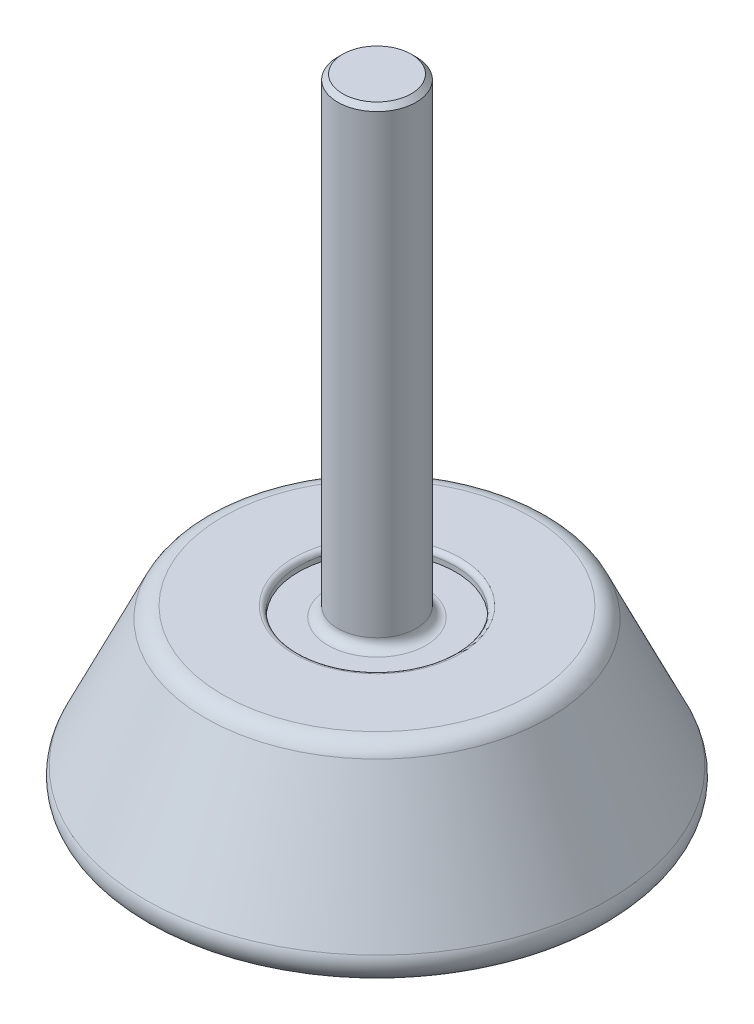
from build123d import *

# Parameters (mm, degrees)
REDONDEO1_R   = 2
REDONDEO2_R   = 1
REDONDEO3_R   = 0.5
CHAFL_N1_SIZE = 0.5


with BuildPart() as part:
    # Croquis2 → Revolución1 (revolve)
    with BuildSketch(Plane.XY):
        Polygon((0, 0), (25, 0), (17, 17), (8, 17), (8, 16), (4, 16), (4, 64), (0, 64), align=None)
    revolve(axis=Axis((0, 64, 0), (0, -1, 0)))

    # Redondeo1
    redondeo1_edges = [part.edges().sort_by_distance(p)[0] for p in [
        (-17, 17, 0),
        (-25, 0, 0),
    ]]
    fillet(redondeo1_edges, radius=REDONDEO1_R)

    # Redondeo2
    redondeo2_edges = [part.edges().sort_by_distance(p)[0] for p in [
        (-4, 16, 0),
    ]]
    fillet(redondeo2_edges, radius=REDONDEO2_R)

    # Redondeo3
    redondeo3_edges = [part.edges().sort_by_distance(p)[0] for p in [
        (-8, 17, 0),
    ]]
    fillet(redondeo3_edges, radius=REDONDEO3_R)

    # Chaflán1
    chafl_n1_edges = [part.edges().sort_by_distance(p)[0] for p in [
        (-4, 64, 0),
    ]]
    chamfer(chafl_n1_edges, length=CHAFL_N1_SIZE)


solid = part.part
